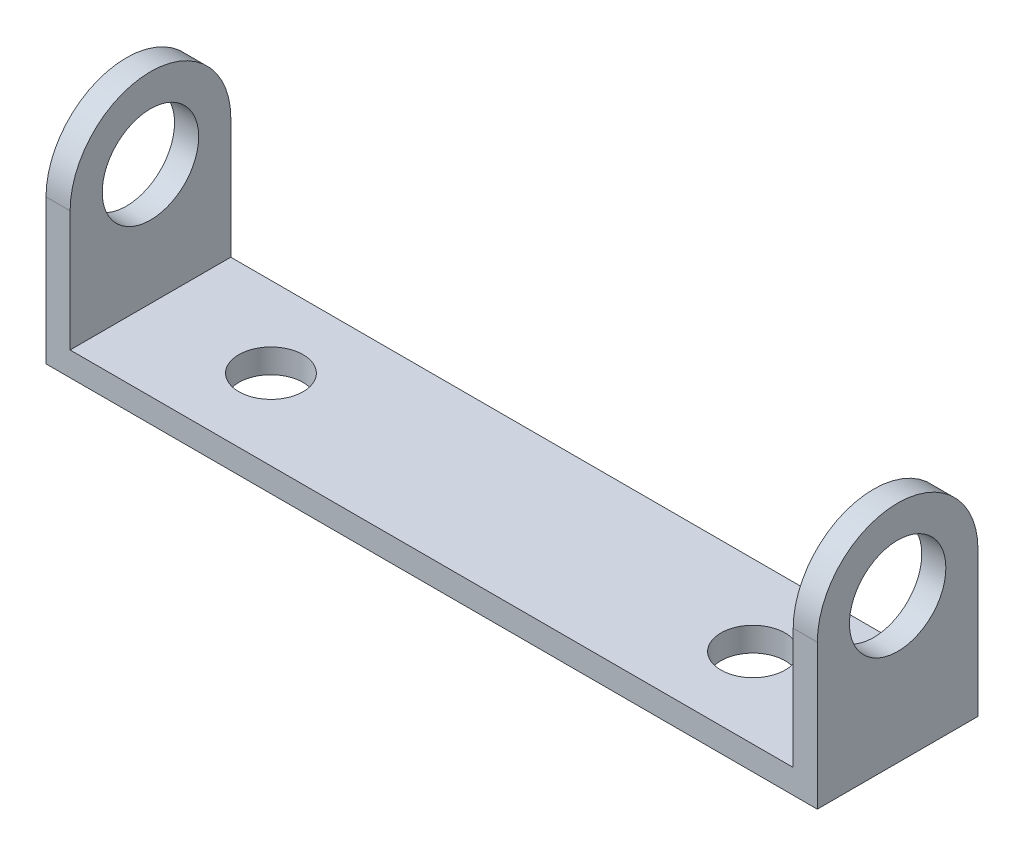
from build123d import *

# Parameters (mm, degrees)
BOSS_EXTRUDE1_DEPTH = 10
CUT_EXTRUDE1_REACH  = 51.528
SKETCH3_R           = 2
CUT_EXTRUDE2_DEPTH  = 10


with BuildPart() as part:
    # Sketch1 → Boss-Extrude1 (new body)
    with BuildSketch(Plane.XY):
        Polygon((-22.5, 7), (-22.5, -5.5), (22.5, -5.5), (22.5, 7), (24, 7), (24, -7), (-24, -7), (-24, 7), align=None)
    extrude(amount=BOSS_EXTRUDE1_DEPTH)

    # Cut-Extrude1: up to this face of the body (flat: up to its plane)
    cut_extrude1_end = Plane(part.part.faces().sort_by_distance((-24, 0, 5))[0])
    # Sketch2 → Cut-Extrude1 (cut, up to the picked face)
    with BuildSketch(Plane(origin=(24, 0, 0), x_dir=(0, 0, -1), z_dir=(1, 0, 0)), mode=Mode.PRIVATE) as cut_extrude1_sk1:
        with BuildLine():
            ThreePointArc((-10, 2), (-8.535533906, 5.535533906), (-5, 7))
            Line((-5, 7), (-10, 7))
            Line((-10, 7), (-10, 2))
        make_face()
    cut_extrude1_tool1 = split(extrude(cut_extrude1_sk1.sketch, amount=-CUT_EXTRUDE1_REACH, mode=Mode.PRIVATE), bisect_by=cut_extrude1_end, keep=Keep.BOTH, mode=Mode.PRIVATE)
    # Sketch2 → Cut-Extrude1 (cut, up to the picked face)
    with BuildSketch(Plane(origin=(24, 0, 0), x_dir=(0, 0, -1), z_dir=(1, 0, 0)), mode=Mode.PRIVATE) as cut_extrude1_sk2:
        with BuildLine():
            ThreePointArc((-5, 7), (-1.464466094, 5.535533906), (0, 2))
            Line((0, 2), (0, 7))
            Line((0, 7), (-5, 7))
        make_face()
    cut_extrude1_tool2 = split(extrude(cut_extrude1_sk2.sketch, amount=-CUT_EXTRUDE1_REACH, mode=Mode.PRIVATE), bisect_by=cut_extrude1_end, keep=Keep.BOTH, mode=Mode.PRIVATE)
    # Sketch2 → Cut-Extrude1 (cut, up to the picked face)
    with BuildSketch(Plane(origin=(24, 0, 0), x_dir=(0, 0, -1), z_dir=(1, 0, 0)), mode=Mode.PRIVATE) as cut_extrude1_sk3:
        with BuildLine():
            ThreePointArc((-8, 2), (-5, -1), (-2, 2))
            Line((-2, 2), (-8, 2))
        make_face()
    cut_extrude1_tool3 = split(extrude(cut_extrude1_sk3.sketch, amount=-CUT_EXTRUDE1_REACH, mode=Mode.PRIVATE), bisect_by=cut_extrude1_end, keep=Keep.BOTH, mode=Mode.PRIVATE)
    # Sketch2 → Cut-Extrude1 (cut, up to the picked face)
    with BuildSketch(Plane(origin=(24, 0, 0), x_dir=(0, 0, -1), z_dir=(1, 0, 0)), mode=Mode.PRIVATE) as cut_extrude1_sk4:
        with BuildLine():
            Line((-8, 2), (-2, 2))
            ThreePointArc((-2, 2), (-5, 5), (-8, 2))
        make_face()
    cut_extrude1_tool4 = split(extrude(cut_extrude1_sk4.sketch, amount=-CUT_EXTRUDE1_REACH, mode=Mode.PRIVATE), bisect_by=cut_extrude1_end, keep=Keep.BOTH, mode=Mode.PRIVATE)
    # Sketch2 → Cut-Extrude1 (cut, up to the picked face)
    with BuildSketch(Plane(origin=(24, 0, 0), x_dir=(0, 0, -1), z_dir=(1, 0, 0)), mode=Mode.PRIVATE) as cut_extrude1_sk5:
        with BuildLine():
            ThreePointArc((-8, 2), (-5, -1), (-2, 2))
            Line((-2, 2), (-8, 2))
        make_face()
    cut_extrude1_tool5 = split(extrude(cut_extrude1_sk5.sketch, amount=-CUT_EXTRUDE1_REACH, mode=Mode.PRIVATE), bisect_by=cut_extrude1_end, keep=Keep.BOTH, mode=Mode.PRIVATE)
    # Sketch2 → Cut-Extrude1 (cut, up to the picked face)
    with BuildSketch(Plane(origin=(24, 0, 0), x_dir=(0, 0, -1), z_dir=(1, 0, 0)), mode=Mode.PRIVATE) as cut_extrude1_sk6:
        with BuildLine():
            Line((-8, 2), (-2, 2))
            ThreePointArc((-2, 2), (-5, 5), (-8, 2))
        make_face()
    cut_extrude1_tool6 = split(extrude(cut_extrude1_sk6.sketch, amount=-CUT_EXTRUDE1_REACH, mode=Mode.PRIVATE), bisect_by=cut_extrude1_end, keep=Keep.BOTH, mode=Mode.PRIVATE)
    add(cut_extrude1_tool1.solids().sort_by(Axis((24, 5.88316, 8.88316), (-1, 0, 0)))[0], mode=Mode.SUBTRACT)
    add(cut_extrude1_tool2.solids().sort_by(Axis((24, 5.88316, 1.11684), (-1, 0, 0)))[0], mode=Mode.SUBTRACT)
    add(cut_extrude1_tool3.solids().sort_by(Axis((24, 0.72676, 5), (-1, 0, 0)))[0], mode=Mode.SUBTRACT)
    add(cut_extrude1_tool4.solids().sort_by(Axis((24, 3.27324, 5), (-1, 0, 0)))[0], mode=Mode.SUBTRACT)
    add(cut_extrude1_tool5.solids().sort_by(Axis((24, 0.72676, 5), (-1, 0, 0)))[0], mode=Mode.SUBTRACT)
    add(cut_extrude1_tool6.solids().sort_by(Axis((24, 3.27324, 5), (-1, 0, 0)))[0], mode=Mode.SUBTRACT)

    # Sketch3 → Cut-Extrude2 (cut)
    with BuildSketch(Plane(origin=(0, -5.5, 0), x_dir=(1, 0, 0), z_dir=(0, 1, 0))):
        with Locations(Location((15, -5, 0), (0, 0, 270))):
            Circle(SKETCH3_R)
        with Locations(Location((-15, -5, 0), (0, 0, 270))):
            Circle(SKETCH3_R)
    extrude(amount=-CUT_EXTRUDE2_DEPTH, mode=Mode.SUBTRACT)


solid = part.part
